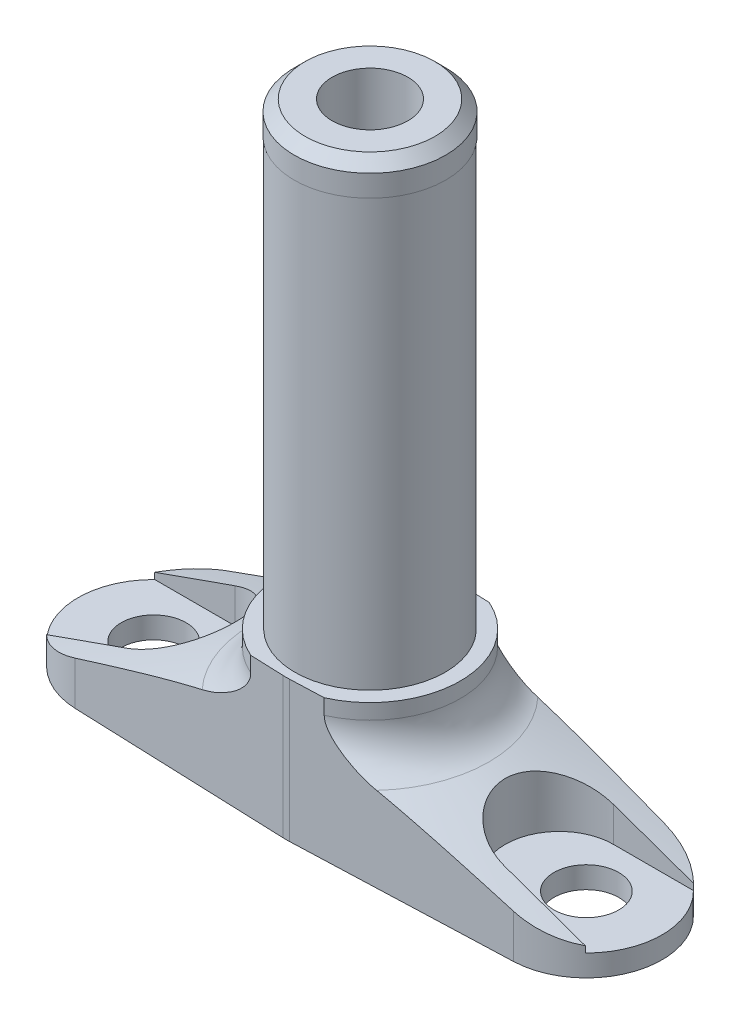
from build123d import *

# Parameters (mm, degrees)
SZKIC1_W                        = 27
SZKIC1_H                        = 25
ZAOKR_GLENIE1_R                 = 4
SZKIC4_R                        = 3
WYTNIJ_WYCI_GNI_CIE3_DEPTH      = 24.0000001
WYTNIJ_WYCI_GNI_CIE3_DEPTH_BACK = 3
WYTNIJ_WYCI_GNI_CIE2_DEPTH      = 24.0000001
SZKIC5_OUTSIDE_W                = 72.072
SZKIC5_OUTSIDE_H                = 72.072
WYTNIJ_WYCI_GNI_CIE4_DEPTH      = 26.0000001
SZKIC8_W                        = 8.35
SZKIC8_H                        = 12
SZKIC10_R                       = 3.5
WYTNIJ_WYCI_GNI_CIE5_DEPTH      = 56.423393859


with BuildPart() as part:
    # Szkic1 → Obrót1 (revolve)
    with BuildSketch(Plane.XY):
        with Locations((13.5, 12.5)):
            Rectangle(SZKIC1_W, SZKIC1_H)
    revolve(axis=Axis((0, 0, 0), (0, 1, 0)))

    # Szkic2 → Wycięcie-obrót1 (revolve, cut)
    with BuildSketch(Plane.XY):
        Polygon((27, 25), (27, 2), (8.35, 8.788044869), (8.35, 25), align=None)
    revolve(axis=Axis((0, 0, 0), (0, 1, 0)), mode=Mode.SUBTRACT)

    # Zaokrąglenie1
    zaokr_glenie1_edges = [part.edges().sort_by_distance(p)[0] for p in [
        (-8.35, 8.788044869, 0),
    ]]
    fillet(zaokr_glenie1_edges, radius=ZAOKR_GLENIE1_R)

    # Szkic4 → Wytnij-wyciągnięcie3 (cut, two sides)
    with BuildSketch(Plane(origin=(0, 2, 0), x_dir=(1, 0, 0), z_dir=(0, 1, 0))) as wytnij_wyci_gni_cie3_sk:
        with Locations((-20, 0)):
            Circle(SZKIC4_R)
        with Locations((20, 0)):
            Circle(SZKIC4_R)
    extrude(amount=WYTNIJ_WYCI_GNI_CIE3_DEPTH, mode=Mode.SUBTRACT)
    extrude(wytnij_wyci_gni_cie3_sk.sketch, amount=-WYTNIJ_WYCI_GNI_CIE3_DEPTH_BACK, mode=Mode.SUBTRACT)

    # Szkic3 → Wytnij-wyciągnięcie2 (cut, through all)
    with BuildSketch(Plane(origin=(0, 2, 0), x_dir=(1, 0, 0), z_dir=(0, 1, 0))):
        with BuildLine():
            Line((-17.5, 5), (-26.532998323, 5))
            ThreePointArc((-26.532998323, 5), (-27, 0), (-26.532998323, -5))
            Line((-26.532998323, -5), (-17.5, -5))
            ThreePointArc((-17.5, -5), (-12.5, 0), (-17.5, 5))
        make_face()
        with BuildLine():
            Line((17.5, 5), (26.532998323, 5))
            ThreePointArc((26.532998323, 5), (27, 0), (26.532998323, -5))
            Line((26.532998323, -5), (17.5, -5))
            ThreePointArc((17.5, -5), (12.5, 0), (17.5, 5))
        make_face()
    extrude(amount=WYTNIJ_WYCI_GNI_CIE2_DEPTH, mode=Mode.SUBTRACT)

    # Szkic5 outside → Wytnij-wyciągnięcie4 (cut, through all)
    with BuildSketch(Plane.XZ):
        Rectangle(SZKIC5_OUTSIDE_W, SZKIC5_OUTSIDE_H)
        with BuildLine():
            Line((-20.2625, 6.995076393), (-0.290625, 7.744548864))
            ThreePointArc((-0.290625, 7.744548864), (0, 7.75), (0.290625, 7.744548864))
            Line((0.290625, 7.744548864), (20.2625, 6.995076393))
            ThreePointArc((20.2625, 6.995076393), (27, 0), (20.2625, -6.995076393))
            Line((20.2625, -6.995076393), (0.290625, -7.744548864))
            ThreePointArc((0.290625, -7.744548864), (0, -7.75), (-0.290625, -7.744548864))
            Line((-0.290625, -7.744548864), (-20.2625, -6.995076393))
            ThreePointArc((-20.2625, -6.995076393), (-27, 0), (-20.2625, 6.995076393))
        make_face(mode=Mode.SUBTRACT)
    extrude(amount=-WYTNIJ_WYCI_GNI_CIE4_DEPTH, mode=Mode.SUBTRACT)

    # Szkic8 → Wycięcie-obrót2 (revolve, cut)
    with BuildSketch(Plane.XY):
        with Locations((4.175, 19)):
            Rectangle(SZKIC8_W, SZKIC8_H)
    revolve(axis=Axis((0, 25, 0), (0, -1, 0)), mode=Mode.SUBTRACT)

    # Szkic9 → Obrót2 (revolve)
    with BuildSketch(Plane.XY):
        Polygon((6, 55.423393759), (0, 55.423393759), (0, 13), (6.95, 13), (6.95, 52.423393759), (7, 52.423393759), (7, 54.423393759), align=None)
    revolve(axis=Axis((0, 13, 0), (0, 1, 0)))

    # Szkic10 → Wytnij-wyciągnięcie5 (cut, through all)
    with BuildSketch(Plane(origin=(0, 55.423393759, 0), x_dir=(1, 0, 0), z_dir=(0, 1, 0))):
        Circle(SZKIC10_R)
    extrude(amount=-WYTNIJ_WYCI_GNI_CIE5_DEPTH, mode=Mode.SUBTRACT)


solid = part.part
